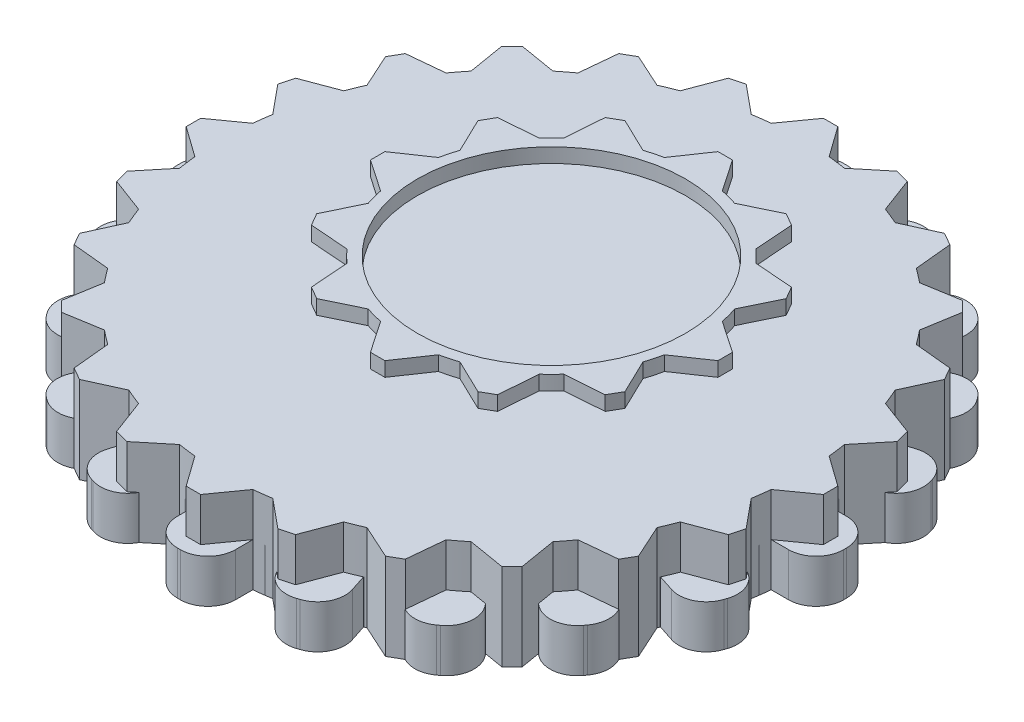
from build123d import *

# Parameters (mm, degrees)
BOSS_EXTRUDE3_DEPTH = 3
BOSS_EXTRUDE5_DEPTH = 6
BOSS_EXTRUDE6_DEPTH = 5.5
SKETCH6_R           = 9.25
BOSS_EXTRUDE7_DEPTH = 1.5


with BuildPart() as part:
    # Sketch2 → Boss-Extrude3 (new body)
    with BuildSketch(Plane(origin=(0, 0, 0), x_dir=(1, 0, 0), z_dir=(0, 1, 0))):
        with BuildLine():
            Line((-23, -0.1), (-23, 0.1))
            ThreePointArc((-23, 0.1), (-22.443502884, 1.443502884), (-21.1, 2))
            Line((-21.1, 2), (-19.899748742, 2))
            ThreePointArc((-19.899748742, 2), (-19.753766812, 3.128689301), (-19.543819703, 4.247247513))
            Line((-19.543819703, 4.247247513), (-20.685326483, 4.618145549))
            ThreePointArc((-20.685326483, 4.618145549), (-21.791106589, 5.56257098), (-21.905201574, 7.012285219))
            Line((-21.905201574, 7.012285219), (-21.843398175, 7.202496522))
            ThreePointArc((-21.843398175, 7.202496522), (-20.898972744, 8.308276629), (-19.449258505, 8.422371614))
            Line((-19.449258505, 8.422371614), (-18.307751725, 8.051473578))
            ThreePointArc((-18.307751725, 8.051473578), (-17.820130484, 9.079809995), (-17.274805421, 10.078744846))
            Line((-17.274805421, 10.078744846), (-18.245829086, 10.784234835))
            ThreePointArc((-18.245829086, 10.784234835), (-19.005644954, 12.02414164), (-18.666169396, 13.438159103))
            Line((-18.666169396, 13.438159103), (-18.548612345, 13.599962502))
            ThreePointArc((-18.548612345, 13.599962502), (-17.30870554, 14.35977837), (-15.894688077, 14.020302812))
            Line((-15.894688077, 14.020302812), (-14.923664412, 13.314812824))
            ThreePointArc((-14.923664412, 13.314812824), (-14.142135624, 14.142135624), (-13.314812824, 14.923664412))
            Line((-13.314812824, 14.923664412), (-14.020302812, 15.894688077))
            ThreePointArc((-14.020302812, 15.894688077), (-14.35977837, 17.30870554), (-13.599962502, 18.548612345))
            Line((-13.599962502, 18.548612345), (-13.438159103, 18.666169396))
            ThreePointArc((-13.438159103, 18.666169396), (-12.02414164, 19.005644954), (-10.784234835, 18.245829086))
            Line((-10.784234835, 18.245829086), (-10.078744846, 17.274805421))
            ThreePointArc((-10.078744846, 17.274805421), (-9.079809995, 17.820130484), (-8.051473578, 18.307751725))
            Line((-8.051473578, 18.307751725), (-8.422371614, 19.449258505))
            ThreePointArc((-8.422371614, 19.449258505), (-8.308276629, 20.898972744), (-7.202496522, 21.843398175))
            Line((-7.202496522, 21.843398175), (-7.012285219, 21.905201574))
            ThreePointArc((-7.012285219, 21.905201574), (-5.56257098, 21.791106589), (-4.618145549, 20.685326483))
            Line((-4.618145549, 20.685326483), (-4.247247513, 19.543819703))
            ThreePointArc((-4.247247513, 19.543819703), (-3.128689301, 19.753766812), (-2, 19.899748742))
            Line((-2, 19.899748742), (-2, 21.1))
            ThreePointArc((-2, 21.1), (-1.443502884, 22.443502884), (-0.1, 23))
            Line((-0.1, 23), (0.1, 23))
            ThreePointArc((0.1, 23), (1.443502884, 22.443502884), (2, 21.1))
            Line((2, 21.1), (2, 19.899748742))
            ThreePointArc((2, 19.899748742), (3.128689301, 19.753766812), (4.247247513, 19.543819703))
            Line((4.247247513, 19.543819703), (4.618145549, 20.685326483))
            ThreePointArc((4.618145549, 20.685326483), (5.56257098, 21.791106589), (7.012285219, 21.905201574))
            Line((7.012285219, 21.905201574), (7.202496522, 21.843398175))
            ThreePointArc((7.202496522, 21.843398175), (8.308276629, 20.898972744), (8.422371614, 19.449258505))
            Line((8.422371614, 19.449258505), (8.051473578, 18.307751725))
            ThreePointArc((8.051473578, 18.307751725), (9.079809995, 17.820130484), (10.078744846, 17.274805421))
            Line((10.078744846, 17.274805421), (10.784234835, 18.245829086))
            ThreePointArc((10.784234835, 18.245829086), (12.02414164, 19.005644954), (13.438159103, 18.666169396))
            Line((13.438159103, 18.666169396), (13.599962502, 18.548612345))
            ThreePointArc((13.599962502, 18.548612345), (14.35977837, 17.30870554), (14.020302812, 15.894688077))
            Line((14.020302812, 15.894688077), (13.314812824, 14.923664412))
            ThreePointArc((13.314812824, 14.923664412), (14.142135624, 14.142135624), (14.923664412, 13.314812824))
            Line((14.923664412, 13.314812824), (15.894688077, 14.020302812))
            ThreePointArc((15.894688077, 14.020302812), (17.30870554, 14.35977837), (18.548612345, 13.599962502))
            Line((18.548612345, 13.599962502), (18.666169396, 13.438159103))
            ThreePointArc((18.666169396, 13.438159103), (19.005644954, 12.02414164), (18.245829086, 10.784234835))
            Line((18.245829086, 10.784234835), (17.274805421, 10.078744846))
            ThreePointArc((17.274805421, 10.078744846), (17.820130484, 9.079809995), (18.307751725, 8.051473578))
            Line((18.307751725, 8.051473578), (19.449258505, 8.422371614))
            ThreePointArc((19.449258505, 8.422371614), (20.898972744, 8.308276629), (21.843398175, 7.202496522))
            Line((21.843398175, 7.202496522), (21.905201574, 7.012285219))
            ThreePointArc((21.905201574, 7.012285219), (21.791106589, 5.56257098), (20.685326483, 4.618145549))
            Line((20.685326483, 4.618145549), (19.543819703, 4.247247513))
            ThreePointArc((19.543819703, 4.247247513), (19.753766812, 3.128689301), (19.899748742, 2))
            Line((19.899748742, 2), (21.1, 2))
            ThreePointArc((21.1, 2), (22.443502884, 1.443502884), (23, 0.1))
            Line((23, 0.1), (23, -0.1))
            ThreePointArc((23, -0.1), (22.443502884, -1.443502884), (21.1, -2))
            Line((21.1, -2), (19.899748742, -2))
            ThreePointArc((19.899748742, -2), (19.753766812, -3.128689301), (19.543819703, -4.247247513))
            Line((19.543819703, -4.247247513), (20.685326483, -4.618145549))
            ThreePointArc((20.685326483, -4.618145549), (21.791106589, -5.56257098), (21.905201574, -7.012285219))
            Line((21.905201574, -7.012285219), (21.843398175, -7.202496522))
            ThreePointArc((21.843398175, -7.202496522), (20.898972744, -8.308276629), (19.449258505, -8.422371614))
            Line((19.449258505, -8.422371614), (18.307751725, -8.051473578))
            ThreePointArc((18.307751725, -8.051473578), (17.820130484, -9.079809995), (17.274805421, -10.078744846))
            Line((17.274805421, -10.078744846), (18.245829086, -10.784234835))
            ThreePointArc((18.245829086, -10.784234835), (19.005644954, -12.02414164), (18.666169396, -13.438159103))
            Line((18.666169396, -13.438159103), (18.548612345, -13.599962502))
            ThreePointArc((18.548612345, -13.599962502), (17.30870554, -14.35977837), (15.894688077, -14.020302812))
            Line((15.894688077, -14.020302812), (14.923664412, -13.314812824))
            ThreePointArc((14.923664412, -13.314812824), (14.142135624, -14.142135624), (13.314812824, -14.923664412))
            Line((13.314812824, -14.923664412), (14.020302812, -15.894688077))
            ThreePointArc((14.020302812, -15.894688077), (14.35977837, -17.30870554), (13.599962502, -18.548612345))
            Line((13.599962502, -18.548612345), (13.438159103, -18.666169396))
            ThreePointArc((13.438159103, -18.666169396), (12.02414164, -19.005644954), (10.784234835, -18.245829086))
            Line((10.784234835, -18.245829086), (10.078744846, -17.274805421))
            ThreePointArc((10.078744846, -17.274805421), (9.079809995, -17.820130484), (8.051473578, -18.307751725))
            Line((8.051473578, -18.307751725), (8.422371614, -19.449258505))
            ThreePointArc((8.422371614, -19.449258505), (8.308276629, -20.898972744), (7.202496522, -21.843398175))
            Line((7.202496522, -21.843398175), (7.012285219, -21.905201574))
            ThreePointArc((7.012285219, -21.905201574), (5.56257098, -21.791106589), (4.618145549, -20.685326483))
            Line((4.618145549, -20.685326483), (4.247247513, -19.543819703))
            ThreePointArc((4.247247513, -19.543819703), (3.128689301, -19.753766812), (2, -19.899748742))
            Line((2, -19.899748742), (2, -21.1))
            ThreePointArc((2, -21.1), (1.443502884, -22.443502884), (0.1, -23))
            Line((0.1, -23), (-0.1, -23))
            ThreePointArc((-0.1, -23), (-1.443502884, -22.443502884), (-2, -21.1))
            Line((-2, -21.1), (-2, -19.899748742))
            ThreePointArc((-2, -19.899748742), (-3.128689301, -19.753766812), (-4.247247513, -19.543819703))
            Line((-4.247247513, -19.543819703), (-4.618145549, -20.685326483))
            ThreePointArc((-4.618145549, -20.685326483), (-5.56257098, -21.791106589), (-7.012285219, -21.905201574))
            Line((-7.012285219, -21.905201574), (-7.202496522, -21.843398175))
            ThreePointArc((-7.202496522, -21.843398175), (-8.308276629, -20.898972744), (-8.422371614, -19.449258505))
            Line((-8.422371614, -19.449258505), (-8.051473578, -18.307751725))
            ThreePointArc((-8.051473578, -18.307751725), (-9.079809995, -17.820130484), (-10.078744846, -17.274805421))
            Line((-10.078744846, -17.274805421), (-10.784234835, -18.245829086))
            ThreePointArc((-10.784234835, -18.245829086), (-12.02414164, -19.005644954), (-13.438159103, -18.666169396))
            Line((-13.438159103, -18.666169396), (-13.599962502, -18.548612345))
            ThreePointArc((-13.599962502, -18.548612345), (-14.35977837, -17.30870554), (-14.020302812, -15.894688077))
            Line((-14.020302812, -15.894688077), (-13.314812824, -14.923664412))
            ThreePointArc((-13.314812824, -14.923664412), (-14.142135624, -14.142135624), (-14.923664412, -13.314812824))
            Line((-14.923664412, -13.314812824), (-15.894688077, -14.020302812))
            ThreePointArc((-15.894688077, -14.020302812), (-17.30870554, -14.35977837), (-18.548612345, -13.599962502))
            Line((-18.548612345, -13.599962502), (-18.666169396, -13.438159103))
            ThreePointArc((-18.666169396, -13.438159103), (-19.005644954, -12.02414164), (-18.245829086, -10.784234835))
            Line((-18.245829086, -10.784234835), (-17.274805421, -10.078744846))
            ThreePointArc((-17.274805421, -10.078744846), (-17.820130484, -9.079809995), (-18.307751725, -8.051473578))
            Line((-18.307751725, -8.051473578), (-19.449258505, -8.422371614))
            ThreePointArc((-19.449258505, -8.422371614), (-20.898972744, -8.308276629), (-21.843398175, -7.202496522))
            Line((-21.843398175, -7.202496522), (-21.905201574, -7.012285219))
            ThreePointArc((-21.905201574, -7.012285219), (-21.791106589, -5.56257098), (-20.685326483, -4.618145549))
            Line((-20.685326483, -4.618145549), (-19.543819703, -4.247247513))
            ThreePointArc((-19.543819703, -4.247247513), (-19.753766812, -3.128689301), (-19.899748742, -2))
            Line((-19.899748742, -2), (-21.1, -2))
            ThreePointArc((-21.1, -2), (-22.443502884, -1.443502884), (-23, -0.1))
        make_face()
    extrude(amount=BOSS_EXTRUDE3_DEPTH)


with BuildPart() as body_2:
    # Sketch3 → Boss-Extrude5 (new body)
    with BuildSketch(Plane(origin=(0, 0, 0), x_dir=(1, 0, 0), z_dir=(0, 1, 0))):
        with BuildLine():
            Line((-22, 0.5), (-22, 0))
            Line((-22, 0), (22, 0))
            Line((22, 0), (22, 0.5))
            Line((22, 0.5), (19.899748742, 2))
            ThreePointArc((19.899748742, 2), (19.828897227, 2.610523844), (19.739319337, 3.218582315))
            Line((19.739319337, 3.218582315), (21.379777701, 5.211056079))
            Line((21.379777701, 5.211056079), (21.120958656, 6.176981905))
            Line((21.120958656, 6.176981905), (18.704043156, 7.08228562))
            ThreePointArc((18.704043156, 7.08228562), (18.47759065, 7.653668647), (18.23368794, 8.217823563))
            Line((18.23368794, 8.217823563), (19.302558883, 10.566987298))
            Line((19.302558883, 10.566987298), (18.802558883, 11.433012702))
            Line((18.802558883, 11.433012702), (16.23368794, 11.681925179))
            ThreePointArc((16.23368794, 11.681925179), (15.867066806, 12.17522858), (15.485460842, 12.657033717))
            Line((15.485460842, 12.657033717), (15.909902577, 15.202795796))
            Line((15.909902577, 15.202795796), (15.202795796, 15.909902577))
            Line((15.202795796, 15.909902577), (12.657033717, 15.485460842))
            ThreePointArc((12.657033717, 15.485460842), (12.17522858, 15.867066806), (11.681925179, 16.23368794))
            Line((11.681925179, 16.23368794), (11.433012702, 18.802558883))
            Line((11.433012702, 18.802558883), (10.566987298, 19.302558883))
            Line((10.566987298, 19.302558883), (8.217823563, 18.23368794))
            ThreePointArc((8.217823563, 18.23368794), (7.653668647, 18.47759065), (7.08228562, 18.704043156))
            Line((7.08228562, 18.704043156), (6.176981905, 21.120958656))
            Line((6.176981905, 21.120958656), (5.211056079, 21.379777701))
            Line((5.211056079, 21.379777701), (3.218582315, 19.739319337))
            ThreePointArc((3.218582315, 19.739319337), (2.610523844, 19.828897227), (2, 19.899748742))
            Line((2, 19.899748742), (0.5, 22))
            Line((0.5, 22), (-0.5, 22))
            Line((-0.5, 22), (-2, 19.899748742))
            ThreePointArc((-2, 19.899748742), (-2.610523844, 19.828897227), (-3.218582315, 19.739319337))
            Line((-3.218582315, 19.739319337), (-5.211056079, 21.379777701))
            Line((-5.211056079, 21.379777701), (-6.176981905, 21.120958656))
            Line((-6.176981905, 21.120958656), (-7.08228562, 18.704043156))
            ThreePointArc((-7.08228562, 18.704043156), (-7.653668647, 18.47759065), (-8.217823563, 18.23368794))
            Line((-8.217823563, 18.23368794), (-10.566987298, 19.302558883))
            Line((-10.566987298, 19.302558883), (-11.433012702, 18.802558883))
            Line((-11.433012702, 18.802558883), (-11.681925179, 16.23368794))
            ThreePointArc((-11.681925179, 16.23368794), (-12.17522858, 15.867066806), (-12.657033717, 15.485460842))
            Line((-12.657033717, 15.485460842), (-15.202795796, 15.909902577))
            Line((-15.202795796, 15.909902577), (-15.909902577, 15.202795796))
            Line((-15.909902577, 15.202795796), (-15.485460842, 12.657033717))
            ThreePointArc((-15.485460842, 12.657033717), (-15.867066806, 12.17522858), (-16.23368794, 11.681925179))
            Line((-16.23368794, 11.681925179), (-18.802558883, 11.433012702))
            Line((-18.802558883, 11.433012702), (-19.302558883, 10.566987298))
            Line((-19.302558883, 10.566987298), (-18.23368794, 8.217823563))
            ThreePointArc((-18.23368794, 8.217823563), (-18.47759065, 7.653668647), (-18.704043156, 7.08228562))
            Line((-18.704043156, 7.08228562), (-21.120958656, 6.176981905))
            Line((-21.120958656, 6.176981905), (-21.379777701, 5.211056079))
            Line((-21.379777701, 5.211056079), (-19.739319337, 3.218582315))
            ThreePointArc((-19.739319337, 3.218582315), (-19.828897227, 2.610523844), (-19.899748742, 2))
            Line((-19.899748742, 2), (-22, 0.5))
        make_face()
        with BuildLine():
            Line((22, 0), (-22, 0))
            Line((-22, 0), (-22, -0.5))
            Line((-22, -0.5), (-19.899748742, -2))
            ThreePointArc((-19.899748742, -2), (-19.828897227, -2.610523844), (-19.739319337, -3.218582315))
            Line((-19.739319337, -3.218582315), (-21.379777701, -5.211056079))
            Line((-21.379777701, -5.211056079), (-21.120958656, -6.176981905))
            Line((-21.120958656, -6.176981905), (-18.704043156, -7.08228562))
            ThreePointArc((-18.704043156, -7.08228562), (-18.47759065, -7.653668647), (-18.23368794, -8.217823563))
            Line((-18.23368794, -8.217823563), (-19.302558883, -10.566987298))
            Line((-19.302558883, -10.566987298), (-18.802558883, -11.433012702))
            Line((-18.802558883, -11.433012702), (-16.23368794, -11.681925179))
            ThreePointArc((-16.23368794, -11.681925179), (-15.867066806, -12.17522858), (-15.485460842, -12.657033717))
            Line((-15.485460842, -12.657033717), (-15.909902577, -15.202795796))
            Line((-15.909902577, -15.202795796), (-15.202795796, -15.909902577))
            Line((-15.202795796, -15.909902577), (-12.657033717, -15.485460842))
            ThreePointArc((-12.657033717, -15.485460842), (-12.17522858, -15.867066806), (-11.681925179, -16.23368794))
            Line((-11.681925179, -16.23368794), (-11.433012702, -18.802558883))
            Line((-11.433012702, -18.802558883), (-10.566987298, -19.302558883))
            Line((-10.566987298, -19.302558883), (-8.217823563, -18.23368794))
            ThreePointArc((-8.217823563, -18.23368794), (-7.653668647, -18.47759065), (-7.08228562, -18.704043156))
            Line((-7.08228562, -18.704043156), (-6.176981905, -21.120958656))
            Line((-6.176981905, -21.120958656), (-5.211056079, -21.379777701))
            Line((-5.211056079, -21.379777701), (-3.218582315, -19.739319337))
            ThreePointArc((-3.218582315, -19.739319337), (-2.610523844, -19.828897227), (-2, -19.899748742))
            Line((-2, -19.899748742), (-0.5, -22))
            Line((-0.5, -22), (0.5, -22))
            Line((0.5, -22), (2, -19.899748742))
            ThreePointArc((2, -19.899748742), (2.610523844, -19.828897227), (3.218582315, -19.739319337))
            Line((3.218582315, -19.739319337), (5.211056079, -21.379777701))
            Line((5.211056079, -21.379777701), (6.176981905, -21.120958656))
            Line((6.176981905, -21.120958656), (7.08228562, -18.704043156))
            ThreePointArc((7.08228562, -18.704043156), (7.653668647, -18.47759065), (8.217823563, -18.23368794))
            Line((8.217823563, -18.23368794), (10.566987298, -19.302558883))
            Line((10.566987298, -19.302558883), (11.433012702, -18.802558883))
            Line((11.433012702, -18.802558883), (11.681925179, -16.23368794))
            ThreePointArc((11.681925179, -16.23368794), (12.17522858, -15.867066806), (12.657033717, -15.485460842))
            Line((12.657033717, -15.485460842), (15.202795796, -15.909902577))
            Line((15.202795796, -15.909902577), (15.909902577, -15.202795796))
            Line((15.909902577, -15.202795796), (15.485460842, -12.657033717))
            ThreePointArc((15.485460842, -12.657033717), (15.867066806, -12.17522858), (16.23368794, -11.681925179))
            Line((16.23368794, -11.681925179), (18.802558883, -11.433012702))
            Line((18.802558883, -11.433012702), (19.302558883, -10.566987298))
            Line((19.302558883, -10.566987298), (18.23368794, -8.217823563))
            ThreePointArc((18.23368794, -8.217823563), (18.47759065, -7.653668647), (18.704043156, -7.08228562))
            Line((18.704043156, -7.08228562), (21.120958656, -6.176981905))
            Line((21.120958656, -6.176981905), (21.379777701, -5.211056079))
            Line((21.379777701, -5.211056079), (19.739319337, -3.218582315))
            ThreePointArc((19.739319337, -3.218582315), (19.828897227, -2.610523844), (19.899748742, -2))
            Line((19.899748742, -2), (22, -0.5))
            Line((22, -0.5), (22, 0))
        make_face()
    extrude(amount=BOSS_EXTRUDE5_DEPTH)


with BuildPart() as body_3:
    # Sketch1 → Boss-Extrude6 (new body)
    with BuildSketch(Plane(origin=(0, 0, 0), x_dir=(1, 0, 0), z_dir=(0, 1, 0))):
        with BuildLine():
            Line((-1.142396869, 15.366895677), (-0.142396869, 15.366895677))
            Line((-0.142396869, 15.366895677), (1.357603131, 13.164854648))
            ThreePointArc((1.357603131, 13.164854648), (1.945793582, 13.026153939), (2.524531809, 12.852177051))
            Line((2.524531809, 12.852177051), (4.924590429, 14.009200522))
            Line((4.924590429, 14.009200522), (5.790615833, 13.509200522))
            Line((5.790615833, 13.509200522), (5.988633424, 10.852177051))
            ThreePointArc((5.988633424, 10.852177051), (6.428670943, 10.437963488), (6.842884505, 9.99792597))
            Line((6.842884505, 9.99792597), (9.499907976, 9.799908378))
            Line((9.499907976, 9.799908378), (9.999907976, 8.933882975))
            Line((9.999907976, 8.933882975), (8.842884505, 6.533824355))
            ThreePointArc((8.842884505, 6.533824355), (9.016861394, 5.955086128), (9.155562102, 5.366895677))
            Line((9.155562102, 5.366895677), (11.357603131, 3.866895677))
            Line((11.357603131, 3.866895677), (11.357603131, 2.866895677))
            Line((11.357603131, 2.866895677), (9.155562102, 1.366895677))
            ThreePointArc((9.155562102, 1.366895677), (9.016861394, 0.778705226), (8.842884505, 0.199966999))
            Line((8.842884505, 0.199966999), (9.999907976, -2.200091622))
            Line((9.999907976, -2.200091622), (9.499907976, -3.066117025))
            Line((9.499907976, -3.066117025), (6.842884505, -3.264134617))
            ThreePointArc((6.842884505, -3.264134617), (6.428670943, -3.704172135), (5.988633424, -4.118385698))
            Line((5.988633424, -4.118385698), (5.790615833, -6.775409169))
            Line((5.790615833, -6.775409169), (4.924590429, -7.275409169))
            Line((4.924590429, -7.275409169), (2.524531809, -6.118385698))
            ThreePointArc((2.524531809, -6.118385698), (1.945793582, -6.292362586), (1.357603131, -6.431063295))
            Line((1.357603131, -6.431063295), (-0.142396869, -8.633104323))
            Line((-0.142396869, -8.633104323), (-1.142396869, -8.633104323))
            Line((-1.142396869, -8.633104323), (-2.642396869, -6.431063295))
            ThreePointArc((-2.642396869, -6.431063295), (-3.23058732, -6.292362586), (-3.809325547, -6.118385698))
            Line((-3.809325547, -6.118385698), (-6.209384167, -7.275409169))
            Line((-6.209384167, -7.275409169), (-7.075409571, -6.775409169))
            Line((-7.075409571, -6.775409169), (-7.273427162, -4.118385698))
            ThreePointArc((-7.273427162, -4.118385698), (-7.713464681, -3.704172135), (-8.127678243, -3.264134617))
            Line((-8.127678243, -3.264134617), (-10.784701714, -3.066117025))
            Line((-10.784701714, -3.066117025), (-11.284701714, -2.200091622))
            Line((-11.284701714, -2.200091622), (-10.127678243, 0.199966999))
            ThreePointArc((-10.127678243, 0.199966999), (-10.301655132, 0.778705226), (-10.44035584, 1.366895677))
            Line((-10.44035584, 1.366895677), (-12.642396869, 2.866895677))
            Line((-12.642396869, 2.866895677), (-12.642396869, 3.866895677))
            Line((-12.642396869, 3.866895677), (-10.44035584, 5.366895677))
            ThreePointArc((-10.44035584, 5.366895677), (-10.301655132, 5.955086128), (-10.127678243, 6.533824355))
            Line((-10.127678243, 6.533824355), (-11.284701714, 8.933882975))
            Line((-11.284701714, 8.933882975), (-10.784701714, 9.799908378))
            Line((-10.784701714, 9.799908378), (-8.127678243, 9.99792597))
            ThreePointArc((-8.127678243, 9.99792597), (-7.713464681, 10.437963488), (-7.273427162, 10.852177051))
            Line((-7.273427162, 10.852177051), (-7.075409571, 13.509200522))
            Line((-7.075409571, 13.509200522), (-6.209384167, 14.009200522))
            Line((-6.209384167, 14.009200522), (-3.809325547, 12.852177051))
            ThreePointArc((-3.809325547, 12.852177051), (-3.23058732, 13.026153939), (-2.642396869, 13.164854648))
            Line((-2.642396869, 13.164854648), (-1.142396869, 15.366895677))
        make_face()
        with BuildLine():
            Line((-2.642396869, 4.866895677), (1.357603131, 4.866895677))
            ThreePointArc((1.357603131, 4.866895677), (1.857603131, 3.366895677), (1.357603131, 1.866895677))
            Line((1.357603131, 1.866895677), (-2.642396869, 1.866895677))
            ThreePointArc((-2.642396869, 1.866895677), (-3.142396869, 3.366895677), (-2.642396869, 4.866895677))
        make_face(mode=Mode.SUBTRACT)
    extrude(amount=BOSS_EXTRUDE6_DEPTH)

    # Sketch6 → Boss-Extrude7 (add)
    with BuildSketch(Plane(origin=(0, 5.5, 0), x_dir=(1, 0, 0), z_dir=(0, 1, 0))):
        with BuildLine():
            Line((-1.142396869, 15.366895677), (-2.642396869, 13.164854648))
            ThreePointArc((-2.642396869, 13.164854648), (-3.23058732, 13.026153939), (-3.809325547, 12.852177051))
            Line((-3.809325547, 12.852177051), (-6.209384167, 14.009200522))
            Line((-6.209384167, 14.009200522), (-7.075409571, 13.509200522))
            Line((-7.075409571, 13.509200522), (-7.273427162, 10.852177051))
            ThreePointArc((-7.273427162, 10.852177051), (-7.713464681, 10.437963488), (-8.127678243, 9.99792597))
            Line((-8.127678243, 9.99792597), (-10.784701714, 9.799908378))
            Line((-10.784701714, 9.799908378), (-11.284701714, 8.933882975))
            Line((-11.284701714, 8.933882975), (-10.127678243, 6.533824355))
            ThreePointArc((-10.127678243, 6.533824355), (-10.301655132, 5.955086128), (-10.44035584, 5.366895677))
            Line((-10.44035584, 5.366895677), (-12.642396869, 3.866895677))
            Line((-12.642396869, 3.866895677), (-12.642396869, 2.866895677))
            Line((-12.642396869, 2.866895677), (-10.44035584, 1.366895677))
            ThreePointArc((-10.44035584, 1.366895677), (-10.301655132, 0.778705226), (-10.127678243, 0.199966999))
            Line((-10.127678243, 0.199966999), (-11.284701714, -2.200091622))
            Line((-11.284701714, -2.200091622), (-10.784701714, -3.066117025))
            Line((-10.784701714, -3.066117025), (-8.127678243, -3.264134617))
            ThreePointArc((-8.127678243, -3.264134617), (-7.713464681, -3.704172135), (-7.273427162, -4.118385698))
            Line((-7.273427162, -4.118385698), (-7.075409571, -6.775409169))
            Line((-7.075409571, -6.775409169), (-6.209384167, -7.275409169))
            Line((-6.209384167, -7.275409169), (-3.809325547, -6.118385698))
            ThreePointArc((-3.809325547, -6.118385698), (-3.23058732, -6.292362586), (-2.642396869, -6.431063295))
            Line((-2.642396869, -6.431063295), (-1.142396869, -8.633104323))
            Line((-1.142396869, -8.633104323), (-0.142396869, -8.633104323))
            Line((-0.142396869, -8.633104323), (1.357603131, -6.431063295))
            ThreePointArc((1.357603131, -6.431063295), (1.945793582, -6.292362586), (2.524531809, -6.118385698))
            Line((2.524531809, -6.118385698), (4.924590429, -7.275409169))
            Line((4.924590429, -7.275409169), (5.790615833, -6.775409169))
            Line((5.790615833, -6.775409169), (5.988633424, -4.118385698))
            ThreePointArc((5.988633424, -4.118385698), (6.428670943, -3.704172135), (6.842884505, -3.264134617))
            Line((6.842884505, -3.264134617), (9.499907976, -3.066117025))
            Line((9.499907976, -3.066117025), (9.999907976, -2.200091622))
            Line((9.999907976, -2.200091622), (8.842884505, 0.199966999))
            ThreePointArc((8.842884505, 0.199966999), (9.016861394, 0.778705226), (9.155562102, 1.366895677))
            Line((9.155562102, 1.366895677), (11.357603131, 2.866895677))
            Line((11.357603131, 2.866895677), (11.357603131, 3.866895677))
            Line((11.357603131, 3.866895677), (9.155562102, 5.366895677))
            ThreePointArc((9.155562102, 5.366895677), (9.016861394, 5.955086128), (8.842884505, 6.533824355))
            Line((8.842884505, 6.533824355), (9.999907976, 8.933882975))
            Line((9.999907976, 8.933882975), (9.499907976, 9.799908378))
            Line((9.499907976, 9.799908378), (6.842884505, 9.99792597))
            ThreePointArc((6.842884505, 9.99792597), (6.428670943, 10.437963488), (5.988633424, 10.852177051))
            Line((5.988633424, 10.852177051), (5.790615833, 13.509200522))
            Line((5.790615833, 13.509200522), (4.924590429, 14.009200522))
            Line((4.924590429, 14.009200522), (2.524531809, 12.852177051))
            ThreePointArc((2.524531809, 12.852177051), (1.945793582, 13.026153939), (1.357603131, 13.164854648))
            Line((1.357603131, 13.164854648), (-0.142396869, 15.366895677))
            Line((-0.142396869, 15.366895677), (-1.142396869, 15.366895677))
        make_face()
        with Locations((-0.642396869, 3.366895677)):
            Circle(SKETCH6_R, mode=Mode.SUBTRACT)
    extrude(amount=BOSS_EXTRUDE7_DEPTH)


solid = Compound([part.part, body_2.part, body_3.part])
